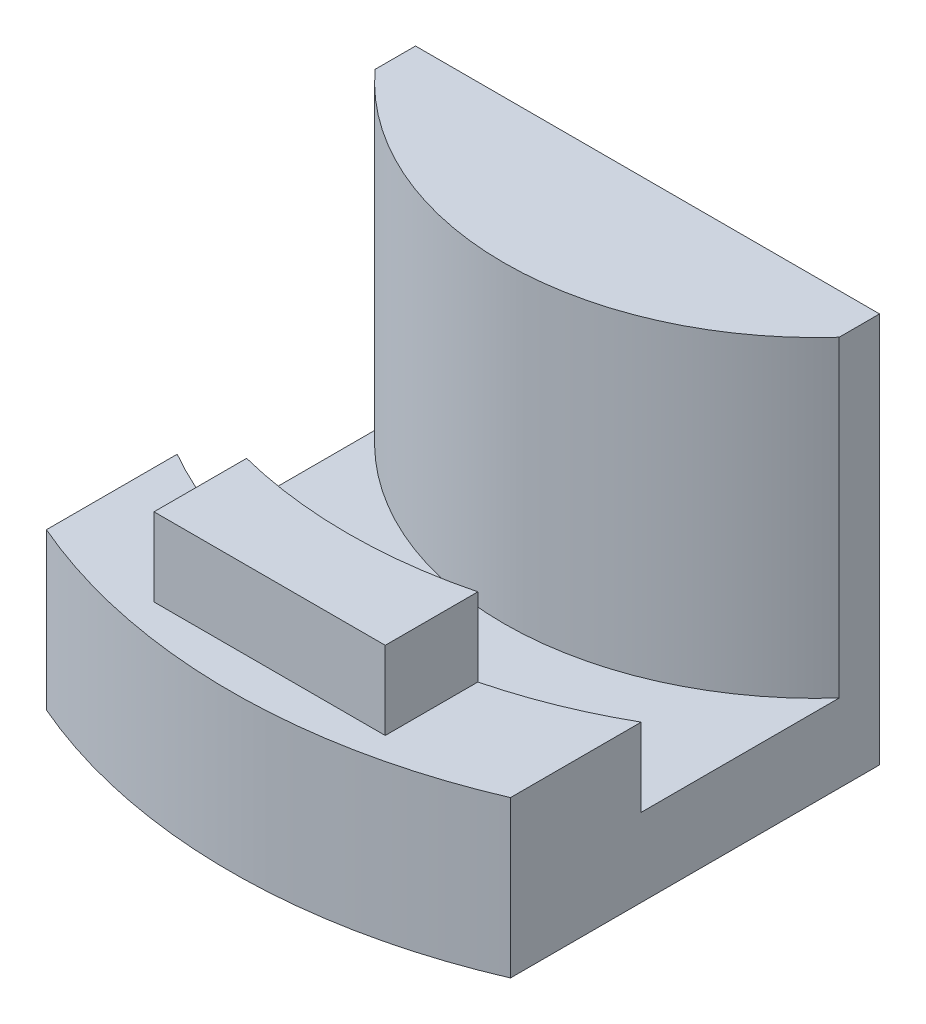
from build123d import *

# Parameters (mm, degrees)
SKETCH1_R           = 38.1
BOSS_EXTRUDE1_DEPTH = 6.35
SKETCH2_R           = 25.4
BOSS_EXTRUDE2_DEPTH = 25.4
SKETCH3_R           = 47.625
SKETCH3_R_2         = 38.1
BOSS_EXTRUDE3_DEPTH = 12.7
CUT_EXTRUDE3_DEPTH  = 32.75
BOSS_EXTRUDE4_DEPTH = 6.35


with BuildPart() as part:
    # Sketch1 → Boss-Extrude1 (new body)
    with BuildSketch(Plane(origin=(0, 0, 0), x_dir=(1, 0, 0), z_dir=(0, 1, 0))):
        Circle(SKETCH1_R)
    extrude(amount=BOSS_EXTRUDE1_DEPTH)

    # Sketch2 → Boss-Extrude2 (add)
    with BuildSketch(Plane(origin=(0, 6.35, 0), x_dir=(1, 0, 0), z_dir=(0, 1, 0))):
        Circle(SKETCH2_R)
    extrude(amount=BOSS_EXTRUDE2_DEPTH)

    # Sketch3 → Boss-Extrude3 (add)
    with BuildSketch(Plane(origin=(0, 0, 0), x_dir=(1, 0, 0), z_dir=(0, 1, 0))):
        Circle(SKETCH3_R)
        Circle(SKETCH3_R_2, mode=Mode.SUBTRACT)
    extrude(amount=BOSS_EXTRUDE3_DEPTH)

    # Sketch4 → Cut-Extrude3 (cut, through all)
    with BuildSketch(Plane(origin=(0, 0, 0), x_dir=(1, 0, 0), z_dir=(0, 1, 0))):
        Polygon((-18.8595, -13.731963353), (18.8595, -13.731963353), (18.8595, -50.573816251), (47.625, -50.573816251), (47.625, 47.625), (19.007906819, 47.625), (-18.8595, 47.625), (-47.625, 47.625), (-47.625, -44.321865457), (-18.8595, -44.321865457), align=None)
    extrude(amount=CUT_EXTRUDE3_DEPTH, mode=Mode.SUBTRACT)

    # Sketch5 → Boss-Extrude4 (add)
    with BuildSketch(Plane(origin=(0, 12.7, 0), x_dir=(1, 0, 0), z_dir=(0, 1, 0))):
        with BuildLine():
            Line((-9.398, -44.45), (9.398, -44.45))
            Line((9.398, -44.45), (9.398, -36.922724656))
            ThreePointArc((9.398, -36.922724656), (0, -38.1), (-9.398, -36.922724656))
            Line((-9.398, -36.922724656), (-9.398, -44.45))
        make_face()
    extrude(amount=BOSS_EXTRUDE4_DEPTH)


solid = part.part
